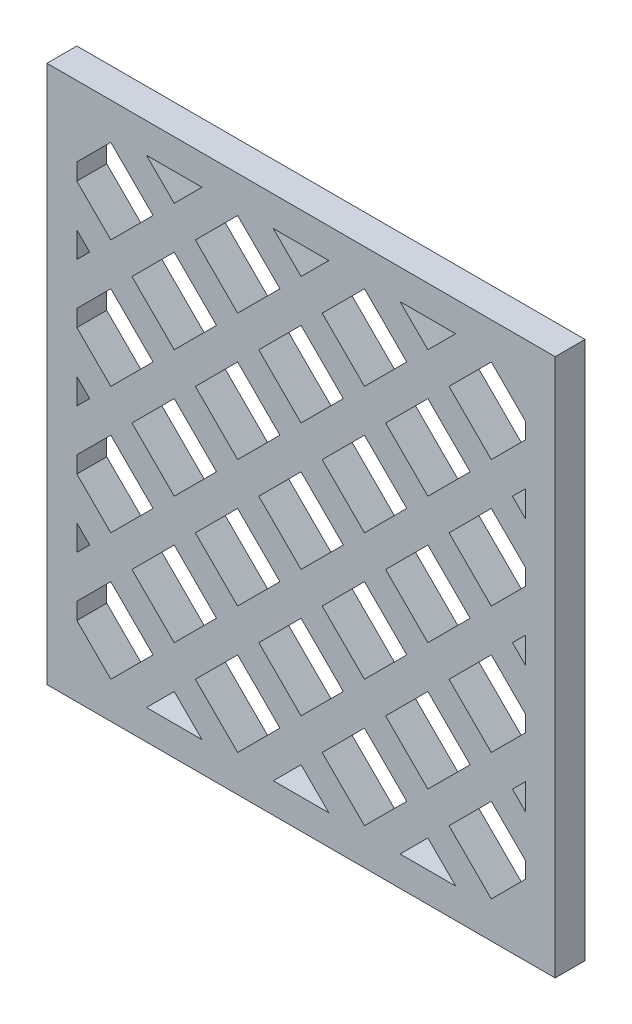
from build123d import *

# Parameters (mm, degrees)
SALIENTE_EXTRUIR1_DEPTH = 5


with BuildPart() as part:
    # Croquis1 → Saliente-Extruir1 (new body)
    with BuildSketch(Plane.XY):
        Polygon((4.84193268, 80.299895435), (-80.15806732, 80.299895435), (-80.15806732, 42.297370118), (-80.15806732, 28.302420752), (-80.15806732, 21.084166683), (-80.15806732, 7.089217316), (-80.15806732, -9.700104565), (-63.368745439, -9.700104565), (-54.373796072, -9.700104565), (-42.155542003, -9.700104565), (-33.160592637, -9.700104565), (-20.942338567, -9.700104565), (-11.947389201, -9.700104565), (4.84193268, -9.700104565), (4.84193268, 7.089217316), (4.84193268, 21.084166683), (4.84193268, 28.302420752), (4.84193268, 42.297370118), align=None)
        Polygon((-69.477872473, 10.551158094), (-62.406804661, 3.480090282), (-69.477872473, -3.59097753), (-75.15806732, 2.089217316), (-75.15806732, 4.870963247), align=None, mode=Mode.SUBTRACT)
        Polygon((-58.871270756, -0.055443624), (-54.226609815, -4.700104565), (-63.515931696, -4.700104565), align=None, mode=Mode.SUBTRACT)
        Polygon((-75.15806732, 16.23135294), (-73.013406379, 14.086692), (-75.15806732, 11.942031059), align=None, mode=Mode.SUBTRACT)
        Polygon((-58.871270756, 21.157759811), (-51.800202944, 14.086692), (-58.871270756, 7.015624188), (-65.942338567, 14.086692), align=None, mode=Mode.SUBTRACT)
        Polygon((-48.264669038, 10.551158094), (-41.193601226, 3.480090282), (-48.264669038, -3.59097753), (-55.33573685, 3.480090282), align=None, mode=Mode.SUBTRACT)
        Polygon((-37.65806732, -0.055443624), (-33.013406379, -4.700104565), (-42.302728261, -4.700104565), align=None, mode=Mode.SUBTRACT)
        Polygon((-37.65806732, 21.157759811), (-30.586999508, 14.086692), (-37.65806732, 7.015624188), (-44.729135132, 14.086692), align=None, mode=Mode.SUBTRACT)
        Polygon((-69.477872473, 31.764361529), (-62.406804661, 24.693293717), (-69.477872473, 17.622225905), (-75.15806732, 23.302420752), (-75.15806732, 26.084166683), align=None, mode=Mode.SUBTRACT)
        Polygon((-58.871270756, 28.228827623), (-65.942338567, 35.299895435), (-58.871270756, 42.370963247), (-51.800202944, 35.299895435), align=None, mode=Mode.SUBTRACT)
        Polygon((-48.264669038, 31.764361529), (-41.193601226, 24.693293717), (-48.264669038, 17.622225905), (-55.33573685, 24.693293717), align=None, mode=Mode.SUBTRACT)
        Polygon((-27.051465602, 10.551158094), (-19.98039779, 3.480090282), (-27.051465602, -3.59097753), (-34.122533414, 3.480090282), align=None, mode=Mode.SUBTRACT)
        Polygon((-16.444863884, -0.055443624), (-11.800202944, -4.700104565), (-21.089524825, -4.700104565), align=None, mode=Mode.SUBTRACT)
        Polygon((-5.838262167, 10.551158094), (-0.15806732, 4.870963247), (-0.15806732, 2.089217316), (-5.838262167, -3.59097753), (-12.909329978, 3.480090282), align=None, mode=Mode.SUBTRACT)
        Polygon((-16.444863884, 21.157759811), (-9.373796072, 14.086692), (-16.444863884, 7.015624188), (-23.515931696, 14.086692), align=None, mode=Mode.SUBTRACT)
        Polygon((-2.302728261, 14.086692), (-0.15806732, 16.23135294), (-0.15806732, 11.942031059), align=None, mode=Mode.SUBTRACT)
        Polygon((-27.051465602, 31.764361529), (-19.98039779, 24.693293717), (-27.051465602, 17.622225905), (-34.122533414, 24.693293717), align=None, mode=Mode.SUBTRACT)
        Polygon((-5.838262167, 31.764361529), (-0.15806732, 26.084166683), (-0.15806732, 23.302420752), (-5.838262167, 17.622225905), (-12.909329978, 24.693293717), align=None, mode=Mode.SUBTRACT)
        Polygon((-73.013406379, 35.299895435), (-75.15806732, 33.155234494), (-75.15806732, 37.444556376), align=None, mode=Mode.SUBTRACT)
        Polygon((-62.406804661, 45.906497153), (-69.477872473, 38.835429341), (-75.15806732, 44.515624188), (-75.15806732, 47.297370118), (-69.477872473, 52.977564965), align=None, mode=Mode.SUBTRACT)
        Polygon((-44.729135132, 35.299895435), (-37.65806732, 42.370963247), (-30.586999508, 35.299895435), (-37.65806732, 28.228827623), align=None, mode=Mode.SUBTRACT)
        Polygon((-55.33573685, 45.906497153), (-48.264669038, 52.977564965), (-41.193601226, 45.906497153), (-48.264669038, 38.835429341), align=None, mode=Mode.SUBTRACT)
        Polygon((-75.15806732, 58.657759811), (-73.013406379, 56.513098871), (-75.15806732, 54.36843793), align=None, mode=Mode.SUBTRACT)
        Polygon((-65.942338567, 56.513098871), (-58.871270756, 63.584166683), (-51.800202944, 56.513098871), (-58.871270756, 49.442031059), align=None, mode=Mode.SUBTRACT)
        Polygon((-62.406804661, 67.119700589), (-69.477872473, 60.048632777), (-75.15806732, 65.728827623), (-75.15806732, 68.510573554), (-69.477872473, 74.1907684), align=None, mode=Mode.SUBTRACT)
        Polygon((-54.226609815, 75.299895435), (-58.871270756, 70.655234494), (-63.515931696, 75.299895435), align=None, mode=Mode.SUBTRACT)
        Polygon((-44.729135132, 56.513098871), (-37.65806732, 63.584166683), (-30.586999508, 56.513098871), (-37.65806732, 49.442031059), align=None, mode=Mode.SUBTRACT)
        Polygon((-55.33573685, 67.119700589), (-48.264669038, 74.1907684), (-41.193601226, 67.119700589), (-48.264669038, 60.048632777), align=None, mode=Mode.SUBTRACT)
        Polygon((-33.013406379, 75.299895435), (-37.65806732, 70.655234494), (-42.302728261, 75.299895435), align=None, mode=Mode.SUBTRACT)
        Polygon((-34.122533414, 45.906497153), (-27.051465602, 52.977564965), (-19.98039779, 45.906497153), (-27.051465602, 38.835429341), align=None, mode=Mode.SUBTRACT)
        Polygon((-16.444863884, 28.228827623), (-23.515931696, 35.299895435), (-16.444863884, 42.370963247), (-9.373796072, 35.299895435), align=None, mode=Mode.SUBTRACT)
        Polygon((-0.15806732, 33.155234494), (-2.302728261, 35.299895435), (-0.15806732, 37.444556376), align=None, mode=Mode.SUBTRACT)
        Polygon((-0.15806732, 44.515624188), (-5.838262167, 38.835429341), (-12.909329978, 45.906497153), (-5.838262167, 52.977564965), (-0.15806732, 47.297370118), align=None, mode=Mode.SUBTRACT)
        Polygon((-34.122533414, 67.119700589), (-27.051465602, 74.1907684), (-19.98039779, 67.119700589), (-27.051465602, 60.048632777), align=None, mode=Mode.SUBTRACT)
        Polygon((-23.515931696, 56.513098871), (-16.444863884, 63.584166683), (-9.373796072, 56.513098871), (-16.444863884, 49.442031059), align=None, mode=Mode.SUBTRACT)
        Polygon((-0.15806732, 54.36843793), (-2.302728261, 56.513098871), (-0.15806732, 58.657759811), align=None, mode=Mode.SUBTRACT)
        Polygon((-11.800202944, 75.299895435), (-16.444863884, 70.655234494), (-21.089524825, 75.299895435), align=None, mode=Mode.SUBTRACT)
        Polygon((-0.15806732, 68.510573554), (-0.15806732, 65.728827623), (-5.838262167, 60.048632777), (-12.909329978, 67.119700589), (-5.838262167, 74.1907684), align=None, mode=Mode.SUBTRACT)
    extrude(amount=SALIENTE_EXTRUIR1_DEPTH)


solid = part.part
